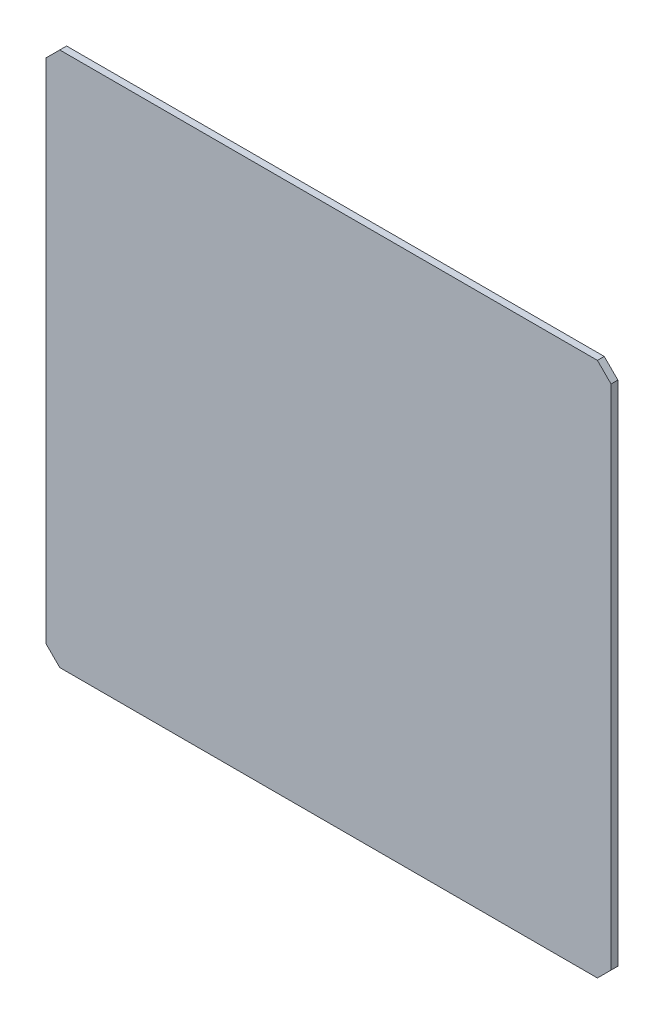
from build123d import *

# Parameters (mm, degrees)
ESTRUSIONE_ESTRUSIONE1_DEPTH = 5


with BuildPart() as part:
    # Schizzo1 → Estrusione-Estrusione1 (new body)
    with BuildSketch(Plane.XY):
        Polygon((-207, 186), (-197, 196), (197, 196), (207, 186), (207, -186), (197, -196), (-197, -196), (-207, -186), align=None)
    extrude(amount=ESTRUSIONE_ESTRUSIONE1_DEPTH)


solid = part.part
